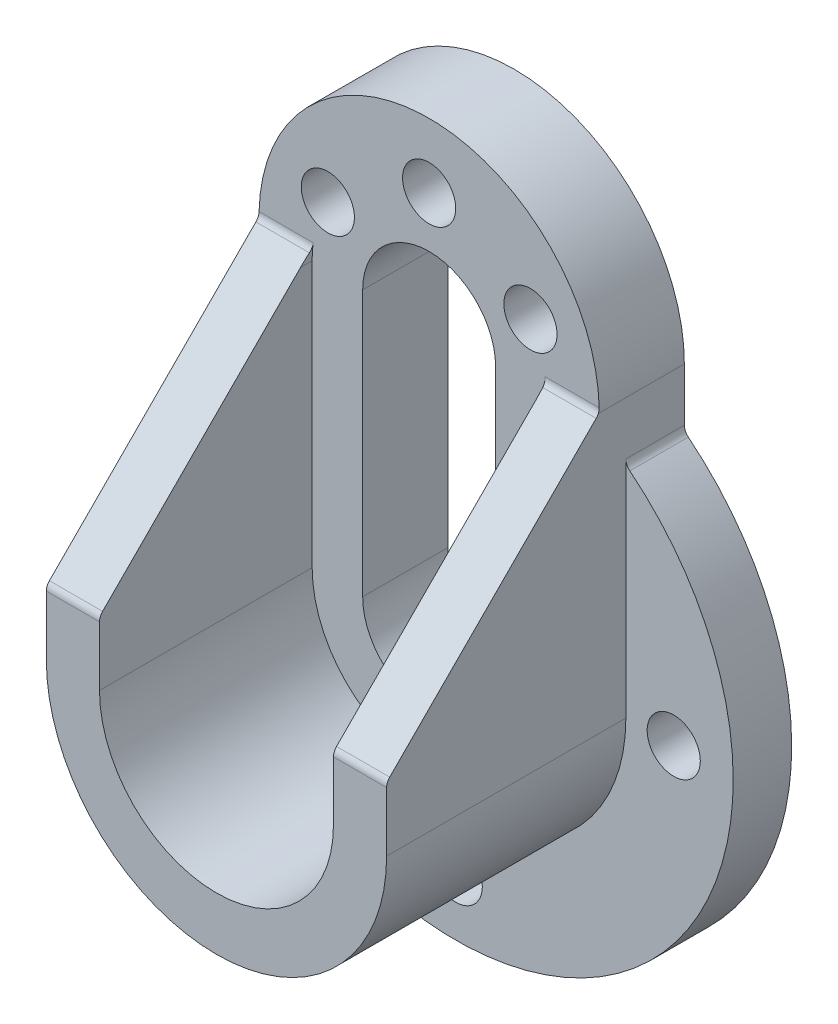
from build123d import *

# Parameters (mm, degrees)
BOSS_EXTRUDE1_DEPTH      = 40
BOSS_EXTRUDE1_DEPTH_BACK = 16
BOSS_EXTRUDE2_START      = -5
SKETCH1_3_R              = 52.187837327
BOSS_EXTRUDE2_DEPTH      = 11
CUT_EXTRUDE1_DEPTH       = 114.785598028
CUT_EXTRUDE3_DEPTH       = 40
CUT_EXTRUDE4_DEPTH       = 126.599298993
FILLET1_R                = 2
F_10_0MM_DOWEL_HOLE1_D   = 10
F_10_0MM_DOWEL_HOLE2_D   = 10
FILLET2_R                = 2
FILLET3_R                = 2


with BuildPart() as part:
    # Sketch1 → Boss-Extrude1 (new, two sides: drawn at the far end of the back side and taken through both)
    with BuildSketch(Plane.XY.offset(-BOSS_EXTRUDE1_DEPTH_BACK)):
        with BuildLine():
            ThreePointArc((-32, 0), (0, -32), (32, 0))
            Line((32, 0), (32, 52.187837327))
            ThreePointArc((32, 52.187837327), (0, 84.187837327), (-32, 52.187837327))
            Line((-32, 52.187837327), (-32, 0))
        make_face()
    extrude(amount=BOSS_EXTRUDE1_DEPTH + BOSS_EXTRUDE1_DEPTH_BACK)

    # Sketch1_3 → Boss-Extrude2 (add)
    with BuildSketch(Plane.XY.offset(BOSS_EXTRUDE2_START)):
        Circle(SKETCH1_3_R)
    extrude(amount=-BOSS_EXTRUDE2_DEPTH)

    # Sketch2 → Cut-Extrude1 (cut, through all)
    with BuildSketch(Plane.XY.offset(40)):
        with BuildLine():
            Line((-12.5, 0), (-12.5, 50))
            ThreePointArc((-12.5, 50), (0, 62.5), (12.5, 50))
            Line((12.5, 50), (12.5, 0))
            ThreePointArc((12.5, 0), (0, -12.5), (-12.5, 0))
        make_face()
    extrude(amount=-CUT_EXTRUDE1_DEPTH, mode=Mode.SUBTRACT)

    # Sketch6 → Cut-Extrude3 (cut)
    with BuildSketch(Plane.XY.offset(40)):
        with BuildLine():
            Line((-22, 0), (-22, 50))
            ThreePointArc((-22, 50), (0, 72), (22, 50))
            Line((22, 50), (22, 0))
            ThreePointArc((22, 0), (0, -22), (-22, 0))
        make_face()
    extrude(amount=-CUT_EXTRUDE3_DEPTH, mode=Mode.SUBTRACT)

    # Sketch7 → Cut-Extrude4 (cut, through all)
    with BuildSketch(Plane(origin=(32, 0, 0), x_dir=(0, 0, -1), z_dir=(1, 0, 0))):
        Polygon((0, 52.187837327), (0, 84.187837327), (-40, 84.187837327), (-40, 12), align=None)
    extrude(amount=-CUT_EXTRUDE4_DEPTH, mode=Mode.SUBTRACT)

    # Fillet1
    fillet1_edges = [part.edges().sort_by_distance(p)[0] for p in [
        (27, 12, 40),
        (-27, 12, 40),
    ]]
    fillet(fillet1_edges, radius=FILLET1_R)

    # Ø10.0mm Dowel Hole1 (through all)
    with Locations(Plane.XY):
        with Locations((-19.052558883, 61), (19.052558883, 61), (0, 72)):
            Hole(F_10_0MM_DOWEL_HOLE1_D / 2)

    # Ø10.0mm Dowel Hole2 (through all)
    with Locations(Plane(origin=(0, 0, -16), x_dir=(-1, 0, 0), z_dir=(0, 0, -1))):
        with Locations((0, -41), (41, 0), (-41, 0)):
            Hole(F_10_0MM_DOWEL_HOLE2_D / 2)

    # Fillet2
    fillet2_edges = [part.edges().sort_by_distance(p)[0] for p in [
        (26.945471299, 52.187837327, 0),
        (-26.945471299, 52.187837327, 0),
    ]]
    fillet(fillet2_edges, radius=FILLET2_R)

    # Fillet3
    fillet3_edges = [part.edges().sort_by_distance(p)[0] for p in [
        (-32, 41.225845835, -10.5),
        (32, 41.225845835, -10.5),
    ]]
    fillet(fillet3_edges, radius=FILLET3_R)


solid = part.part
